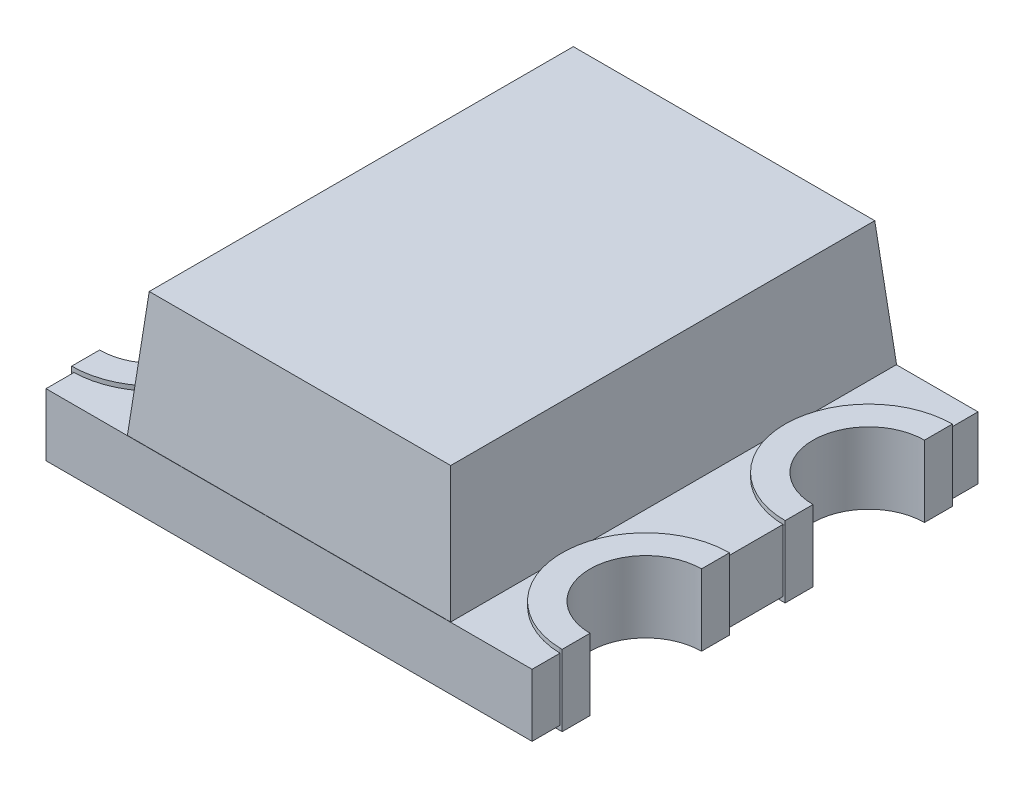
from build123d import *

# Parameters (mm, degrees)
SKETCH1_W             = 2.2
SKETCH1_H             = 2
BOSS_EXTRUDE1_DEPTH   = 0.28
BOSS_EXTRUDE2_DEPTH   = 0.02
CUT_EXTRUDE1_DEPTH    = 2
SKETCH4_W             = 0.125
SKETCH4_H             = 0.28
SKETCH4_W_2           = 0.25
CUT_EXTRUDE2_DEPTH    = 0.01
SKETCH5_W             = 0.125
SKETCH5_H             = 0.28
SKETCH5_W_2           = 0.25
CUT_EXTRUDE3_DEPTH    = 0.01
SKETCH6_W             = 1.45
SKETCH6_H             = 2
BOSS_EXTRUDE3_DEPTH   = 0.56
BOSS_EXTRUDE3_TAPER   = 5
SKETCH8_W             = 1.45
SKETCH8_H             = 2
CUT_EXTRUDE4_DEPTH    = 0.001
SKETCH10_W            = 0.69
SKETCH10_H            = 0.54
BOSS_EXTRUDE5_DEPTH   = 0.2
SKETCH11_W            = 0.71
SKETCH11_H            = 0.56
SKETCH11_W_2          = 0.69
SKETCH11_H_2          = 0.54
CUT_EXTRUDE5_DEPTH    = 0.201
BOSS_EXTRUDE4_DEPTH   = 0.02
BOSS_EXTRUDE6_DEPTH   = 0.02
BODY_MOVE_COPY1_ANGLE = 90
BODY_MOVE_COPY3_ANGLE = 90


with BuildPart() as part:
    # Sketch1 → Boss-Extrude1 (new body)
    with BuildSketch(Plane(origin=(0, 0, 0), x_dir=(1, 0, 0), z_dir=(0, 1, 0))):
        Rectangle(SKETCH1_W, SKETCH1_H)
    extrude(amount=BOSS_EXTRUDE1_DEPTH)

    # Sketch2 → Boss-Extrude2 (add)
    with BuildSketch(Plane(origin=(0, 0.28, 0), x_dir=(1, 0, 0), z_dir=(0, 1, 0))):
        with BuildLine():
            Line((-0.565, 0.875), (-1.1, 0.875))
            Line((-1.1, 0.875), (-1.1, 0.75))
            ThreePointArc((-1.1, 0.75), (-0.923223305, 0.676776695), (-0.85, 0.5))
            ThreePointArc((-0.85, 0.5), (-0.923223305, 0.323223305), (-1.1, 0.25))
            Line((-1.1, 0.25), (-1.1, 0.125))
            Line((-1.1, 0.125), (-0.565, 0.125))
            Line((-0.565, 0.125), (-0.565, 0.875))
        make_face()
        with BuildLine():
            Line((1.1, 0.875), (0.565, 0.875))
            Line((0.565, 0.875), (0.565, 0.125))
            Line((0.565, 0.125), (1.1, 0.125))
            Line((1.1, 0.125), (1.1, 0.25))
            ThreePointArc((1.1, 0.25), (0.85, 0.5), (1.1, 0.75))
            Line((1.1, 0.75), (1.1, 0.875))
        make_face()
        with BuildLine():
            Line((1.1, -0.25), (1.1, -0.125))
            Line((1.1, -0.125), (0.565, -0.125))
            Line((0.565, -0.125), (0.565, -0.875))
            Line((0.565, -0.875), (1.1, -0.875))
            Line((1.1, -0.875), (1.1, -0.75))
            ThreePointArc((1.1, -0.75), (0.85, -0.5), (1.1, -0.25))
        make_face()
        with BuildLine():
            Line((-0.565, -0.125), (-1.1, -0.125))
            Line((-1.1, -0.125), (-1.1, -0.25))
            ThreePointArc((-1.1, -0.25), (-0.923223305, -0.323223305), (-0.85, -0.5))
            ThreePointArc((-0.85, -0.5), (-0.923223305, -0.676776695), (-1.1, -0.75))
            Line((-1.1, -0.75), (-1.1, -0.875))
            Line((-1.1, -0.875), (-0.565, -0.875))
            Line((-0.565, -0.875), (-0.565, -0.125))
        make_face()
    extrude(amount=BOSS_EXTRUDE2_DEPTH)

    # Sketch3 → Cut-Extrude1 (cut)
    with BuildSketch(Plane(origin=(0, 0.28, 0), x_dir=(1, 0, 0), z_dir=(0, 1, 0))):
        with BuildLine():
            Line((-1.1, 0.75), (-1.1, 0.25))
            ThreePointArc((-1.1, 0.25), (-0.85, 0.5), (-1.1, 0.75))
        make_face()
        with BuildLine():
            Line((-1.1, -0.25), (-1.1, -0.75))
            ThreePointArc((-1.1, -0.75), (-0.85, -0.5), (-1.1, -0.25))
        make_face()
        with BuildLine():
            Line((1.1, 0.25), (1.1, 0.75))
            ThreePointArc((1.1, 0.75), (0.85, 0.5), (1.1, 0.25))
        make_face()
        with BuildLine():
            Line((1.1, -0.75), (1.1, -0.25))
            ThreePointArc((1.1, -0.25), (0.85, -0.5), (1.1, -0.75))
        make_face()
    extrude(amount=-CUT_EXTRUDE1_DEPTH, mode=Mode.SUBTRACT)

    # Sketch4 → Cut-Extrude2 (cut)
    with BuildSketch(Plane.ZY.offset(1.1)):
        with Locations((-0.9375, 0.14)):
            Rectangle(SKETCH4_W, SKETCH4_H)
        with Locations((0, 0.14)):
            Rectangle(SKETCH4_W_2, SKETCH4_H)
        with Locations((0.9375, 0.14)):
            Rectangle(SKETCH4_W, SKETCH4_H)
    extrude(amount=-CUT_EXTRUDE2_DEPTH, mode=Mode.SUBTRACT)

    # Sketch5 → Cut-Extrude3 (cut)
    with BuildSketch(Plane(origin=(1.1, 0, 0), x_dir=(0, 0, -1), z_dir=(1, 0, 0))):
        with Locations((-0.9375, 0.14)):
            Rectangle(SKETCH5_W, SKETCH5_H)
        with Locations((0, 0.14)):
            Rectangle(SKETCH5_W_2, SKETCH5_H)
        with Locations((0.9375, 0.14)):
            Rectangle(SKETCH5_W, SKETCH5_H)
    extrude(amount=-CUT_EXTRUDE3_DEPTH, mode=Mode.SUBTRACT)

    # Sketch6 → Boss-Extrude3 (add)
    with BuildSketch(Plane.XZ):
        Rectangle(SKETCH6_W, SKETCH6_H)
    extrude(amount=BOSS_EXTRUDE3_DEPTH, taper=BOSS_EXTRUDE3_TAPER)

    # Sketch8 → Cut-Extrude4 (cut)
    with BuildSketch(Plane.XZ):
        Rectangle(SKETCH8_W, SKETCH8_H)
    extrude(amount=CUT_EXTRUDE4_DEPTH, mode=Mode.SUBTRACT)


with BuildPart() as cut_extrude4_piece_1:
    # of the separate pieces the step leaves, piece 1, a body of its own (cut_extrude4_pieces)
    add(part.part.solids().sort_by_distance((-0.724912511, -0.001, -0.999912511))[0])



with BuildPart() as cut_extrude4_piece_2:
    # of the separate pieces the step leaves, piece 2, a body of its own (cut_extrude4_pieces)
    add(part.part.solids().sort_by_distance((1.09, 0, -1))[0])


with BuildPart() as cut_extrude4_piece_1_1:
    add(cut_extrude4_piece_1.part)

    add(cut_extrude4_piece_2.part)  # Boss-Extrude5 merges Cut-Extrude4 piece 2
    # Sketch10 → Boss-Extrude5 (add)
    with BuildSketch(Plane.XZ):
        with Locations((0.045, 0.23)):
            Rectangle(SKETCH10_W, SKETCH10_H)
    extrude(amount=BOSS_EXTRUDE5_DEPTH)

    # Sketch11 → Cut-Extrude5 (cut)
    with BuildSketch(Plane(origin=(0, -0.001, 0), x_dir=(1, 0, 0), z_dir=(0, 1, 0))):
        with Locations((0.045, -0.23)):
            Rectangle(SKETCH11_W, SKETCH11_H)
        with Locations((0.045, -0.23)):
            Rectangle(SKETCH11_W_2, SKETCH11_H_2, mode=Mode.SUBTRACT)
        with Locations((0.045, -0.23)):
            Rectangle(SKETCH11_W_2, SKETCH11_H_2)
    extrude(amount=-CUT_EXTRUDE5_DEPTH, mode=Mode.SUBTRACT)


with BuildPart() as cut_extrude5_piece_1:
    # of the separate pieces the step leaves, piece 1, a body of its own (cut_extrude5_pieces)
    add(cut_extrude4_piece_1_1.part.solids().sort_by_distance((0.724912511, -0.001, 0.999912511))[0])



with BuildPart() as cut_extrude5_piece_2:
    # of the separate pieces the step leaves, piece 2, a body of its own (cut_extrude5_pieces)
    add(cut_extrude4_piece_1_1.part.solids().sort_by_distance((1.09, 0, -1))[0])


with BuildPart() as cut_extrude5_piece_1_1:
    add(cut_extrude5_piece_1.part)

    add(cut_extrude5_piece_2.part)  # Boss-Extrude4 merges Cut-Extrude5 piece 2
    # Sketch9 → Boss-Extrude4 (add)
    with BuildSketch(Plane.XZ):
        with BuildLine():
            ThreePointArc((-1.1, 0.125), (-0.725, 0.5), (-1.1, 0.875))
            Line((-1.1, 0.875), (-1.1, 0.75))
            ThreePointArc((-1.1, 0.75), (-0.85, 0.5), (-1.1, 0.25))
            Line((-1.1, 0.25), (-1.1, 0.125))
        make_face()
        with BuildLine():
            ThreePointArc((-1.1, -0.875), (-0.725, -0.5), (-1.1, -0.125))
            Line((-1.1, -0.125), (-1.1, -0.25))
            ThreePointArc((-1.1, -0.25), (-0.85, -0.5), (-1.1, -0.75))
            Line((-1.1, -0.75), (-1.1, -0.875))
        make_face()
        with BuildLine():
            ThreePointArc((1.1, 0.875), (0.725, 0.5), (1.1, 0.125))
            Line((1.1, 0.125), (1.1, 0.25))
            ThreePointArc((1.1, 0.25), (0.85, 0.5), (1.1, 0.75))
            Line((1.1, 0.75), (1.1, 0.875))
        make_face()
        with BuildLine():
            ThreePointArc((1.09, -0.125), (0.72486669, -0.5), (1.09, -0.875))
            Line((1.09, -0.875), (1.1, -0.875))
            Line((1.1, -0.875), (1.1, -0.75))
            ThreePointArc((1.1, -0.75), (0.85, -0.5), (1.1, -0.25))
            Line((1.1, -0.25), (1.1, -0.125))
            Line((1.1, -0.125), (1.09, -0.125))
        make_face()
    extrude(amount=BOSS_EXTRUDE4_DEPTH)

    # Sketch12 → Boss-Extrude6 (add)
    with BuildSketch(Plane(origin=(0, 0.28, 0), x_dir=(1, 0, 0), z_dir=(0, 1, 0))):
        with BuildLine():
            Line((0.515, 0.675), (0.515, -0.675))
            ThreePointArc((0.515, -0.675), (0.315, -0.875), (0.115, -0.675))
            Line((0.115, -0.675), (0.115, 0.675))
            ThreePointArc((0.115, 0.675), (0.315, 0.875), (0.515, 0.675))
        make_face()
    extrude(amount=BOSS_EXTRUDE6_DEPTH)


with BuildPart() as cut_extrude5_piece_1_2:
    # Body-Move/Copy1: moved
    add(cut_extrude5_piece_1_1.part.rotate(Axis((0, 0, 0), (-1, 0, 0)), BODY_MOVE_COPY1_ANGLE))


with BuildPart() as cut_extrude5_piece_1_3:
    # Body-Move/Copy2: moved
    add(cut_extrude5_piece_1_2.part.moved(Location((0, 0, 0.28))))


with BuildPart() as cut_extrude5_piece_1_4:
    # Body-Move/Copy3: moved
    add(cut_extrude5_piece_1_3.part.rotate(Axis((0, 0, 0), (-1, 0, 0)), BODY_MOVE_COPY3_ANGLE))


solid = cut_extrude5_piece_1_4.part
